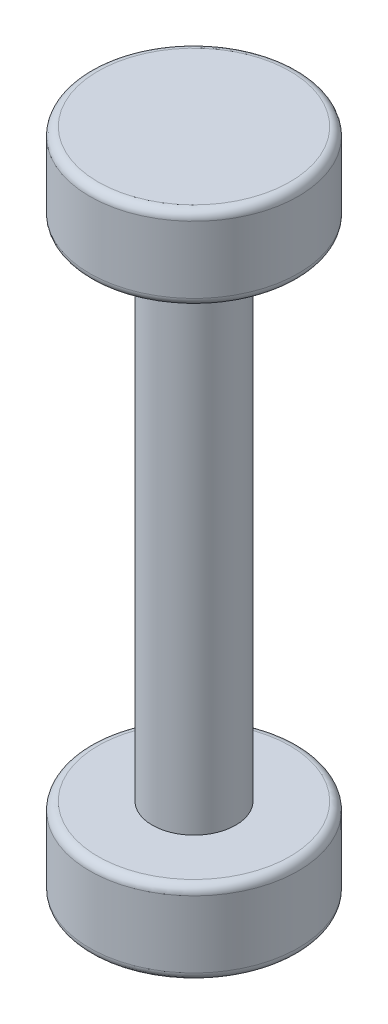
from build123d import *

# Parameters (mm, degrees)
SKETCH1_R           = 2.5
BOSS_EXTRUDE1_DEPTH = 2
SKETCH2_R           = 1
BOSS_EXTRUDE2_DEPTH = 12
SKETCH3_R           = 2.5
BOSS_EXTRUDE3_DEPTH = 2
FILLET1_R           = 0.2


with BuildPart() as part:
    # Sketch1 → Boss-Extrude1 (new body)
    with BuildSketch(Plane(origin=(0, 0, 0), x_dir=(1, 0, 0), z_dir=(0, 1, 0))):
        Circle(SKETCH1_R)
    extrude(amount=-BOSS_EXTRUDE1_DEPTH)

    # Sketch2 → Boss-Extrude2 (add)
    with BuildSketch(Plane.XZ.offset(2)):
        Circle(SKETCH2_R)
    extrude(amount=BOSS_EXTRUDE2_DEPTH)

    # Sketch3 → Boss-Extrude3 (add)
    with BuildSketch(Plane.XZ.offset(14)):
        Circle(SKETCH3_R)
    extrude(amount=BOSS_EXTRUDE3_DEPTH)

    # Fillet1
    fillet1_edges = [part.edges().sort_by_distance(p)[0] for p in [
        (-2.5, 0, 0),
        (-2.5, -2, 0),
        (-2.5, -14, 0),
        (-2.5, -16, 0),
    ]]
    fillet(fillet1_edges, radius=FILLET1_R)


solid = part.part
